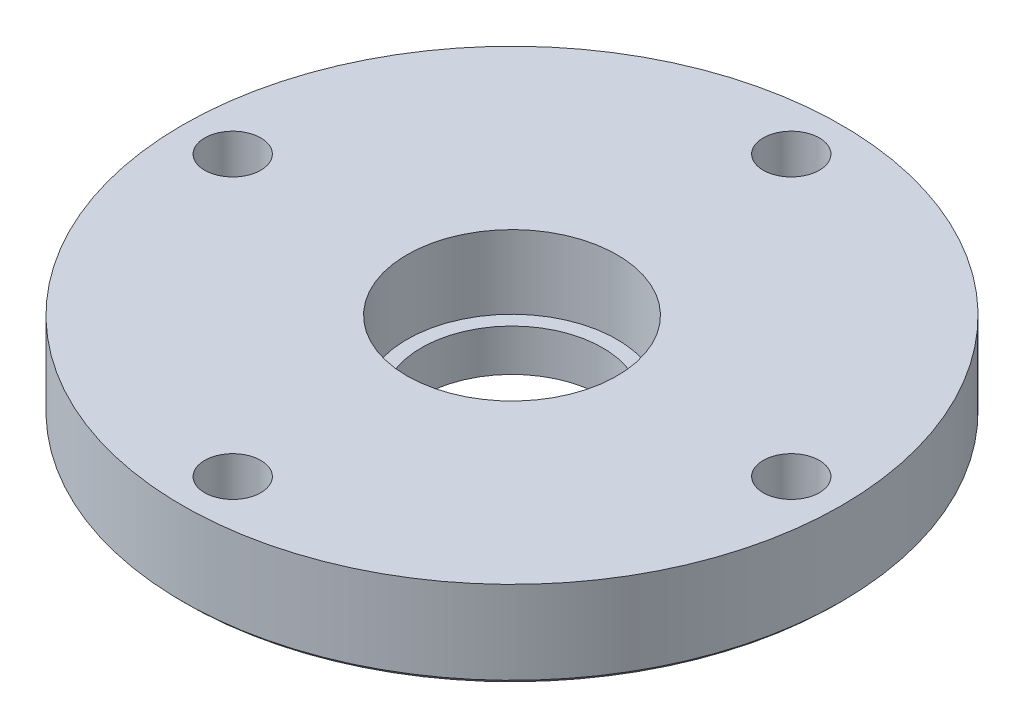
from build123d import *

# Parameters (mm, degrees)
SKETCH2_R                                = 9.50595
BOSS_EXTRUDE1_DEPTH                      = 2.159
SKETCH3_R                                = 9.50595
BOSS_EXTRUDE2_DEPTH                      = 0.381
BOSS_EXTRUDE2_TAPER                      = 45
HOLE1_D                                  = 5.1054
HOLE1_DEPTH                              = 7.9375
HOLE2_D                                  = 5.1054
HOLE2_DEPTH                              = 10.4775
CBORE_FOR_M14_HEX_HEAD_BOLT1_D           = 16.4719
CBORE_FOR_M14_HEX_HEAD_BOLT1_DEPTH       = 10.4775
CBORE_FOR_M14_HEX_HEAD_BOLT1_CBORE_D     = 19.1008
CBORE_FOR_M14_HEX_HEAD_BOLT1_CBORE_DEPTH = 6.6675


with BuildPart() as part:
    # Sketch1 → Revolve1 (revolve)
    with BuildSketch(Plane(origin=(0, 0, 0), x_dir=(-1, 0, 0), z_dir=(0, 0, -1))):
        Polygon((-29.591, 0), (0, 0), (0, 7.9375), (-29.972, 7.9375), (-29.972, 0.381), align=None)
    revolve(axis=Axis((0, 0, 0), (0, 1, 0)))

    # Sketch2 → Boss-Extrude1 (add)
    with BuildSketch(Plane.XZ):
        Circle(SKETCH2_R)
    extrude(amount=BOSS_EXTRUDE1_DEPTH)

    # Sketch3 → Boss-Extrude2 (add)
    with BuildSketch(Plane.XZ.offset(2.159)):
        Circle(SKETCH3_R)
    extrude(amount=BOSS_EXTRUDE2_DEPTH, taper=BOSS_EXTRUDE2_TAPER)

    # Hole1
    with Locations(Plane(origin=(0, 0, 0), x_dir=(-1, 0, 0), z_dir=(0, -1, 0))):
        with Locations((0, -25.4)):
            Hole(HOLE1_D / 2, depth=HOLE1_DEPTH)

    # Hole2
    with Locations(Plane(origin=(0, 7.9375, 0), x_dir=(1, 0, 0), z_dir=(0, 1, 0))):
        with Locations((0, 25.4), (25.4, 0), (-25.4, 0)):
            Hole(HOLE2_D / 2, depth=HOLE2_DEPTH)

    # CBORE for M14 Hex Head Bolt1
    with Locations(Plane(origin=(0, 7.9375, 0), x_dir=(1, 0, 0), z_dir=(0, 1, 0))):
        with Locations((0, 0)):
            CounterBoreHole(CBORE_FOR_M14_HEX_HEAD_BOLT1_D / 2, CBORE_FOR_M14_HEX_HEAD_BOLT1_CBORE_D / 2, CBORE_FOR_M14_HEX_HEAD_BOLT1_CBORE_DEPTH, depth=CBORE_FOR_M14_HEX_HEAD_BOLT1_DEPTH)


solid = part.part
